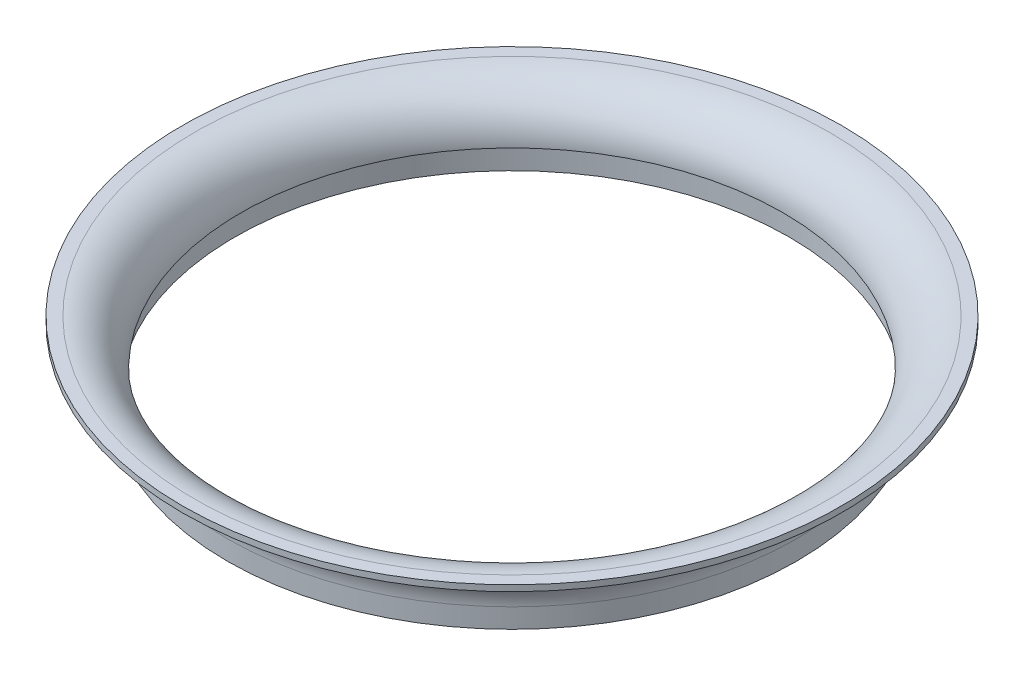
from build123d import *


with BuildPart() as part:
    # Sketch1 → Revolve1 (revolve)
    with BuildSketch(Plane.XY):
        with BuildLine():
            Line((47.5, 0), (47.5, 3.25))
            ThreePointArc((47.5, 3.25), (49.696699141, 8.553300859), (55, 10.75))
            Line((55, 10.75), (55, 11.75))
            Line((55, 11.75), (53, 11.75))
            ThreePointArc((53, 11.75), (47.519922446, 9.480077554), (45.25, 4))
            Line((45.25, 4), (46.25, 4))
            Line((46.25, 4), (46.25, 0))
            Line((46.25, 0), (47.5, 0))
        make_face()
    revolve(axis=Axis((0, 0, 0), (0, 1, 0)))


solid = part.part
